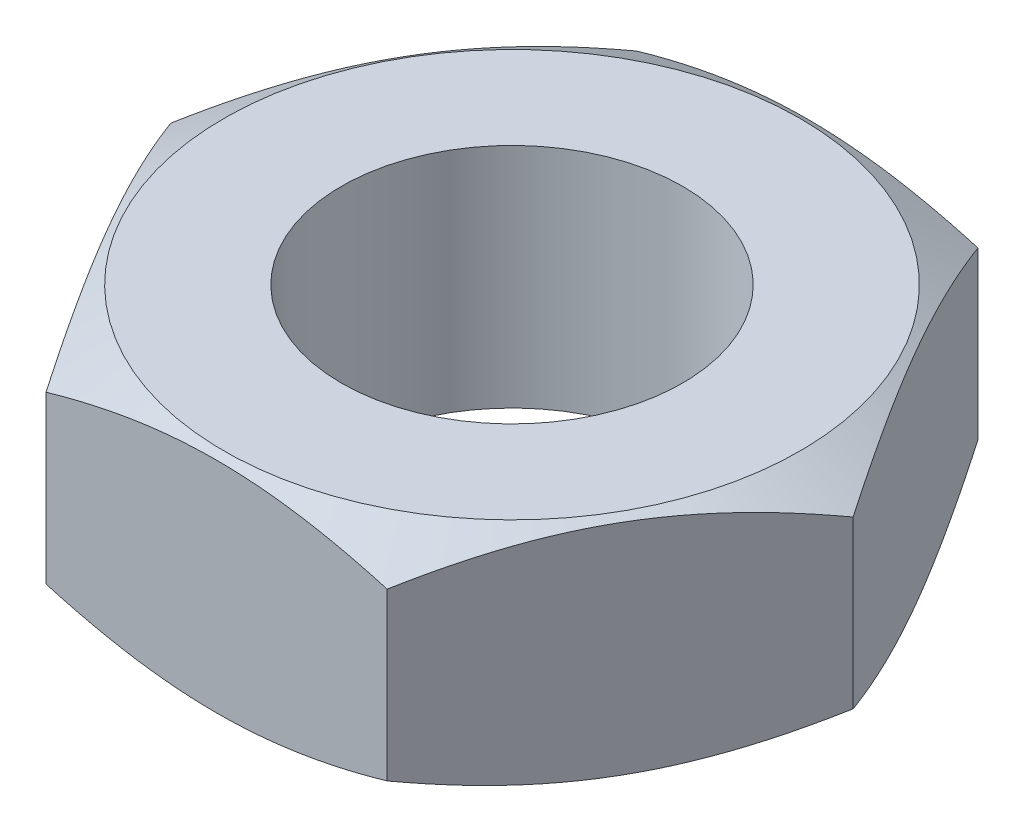
from build123d import *

# Parameters (mm, degrees)
BOSS_EXTRUDE1_DEPTH = 3
SKETCH3_R           = 4.5
CUT_EXTRUDE1_DEPTH  = 7


with BuildPart() as part:
    # Sketch2 → Boss-Extrude1 (new body, symmetric)
    with BuildSketch(Plane(origin=(0, 0, 0), x_dir=(1, 0, 0), z_dir=(0, 1, 0))):
        Polygon((-4.5, 7.794228634), (-9, 0), (-4.5, -7.794228634), (4.5, -7.794228634), (9, 0), (4.5, 7.794228634), align=None)
    extrude(amount=BOSS_EXTRUDE1_DEPTH, both=True)

    # Sketch3 → Cut-Extrude1 (cut, through all)
    with BuildSketch(Plane(origin=(0, 3, 0), x_dir=(1, 0, 0), z_dir=(0, 1, 0))):
        with Locations(Location((0, 0, 0), (0, 0, 270))):  # turned: the seam where the file's is
            Circle(SKETCH3_R)
    extrude(amount=-CUT_EXTRUDE1_DEPTH, mode=Mode.SUBTRACT)

    # Sketch10 → Cut-Revolve1 (revolve, cut)
    with BuildSketch(Plane.XY, mode=Mode.PRIVATE) as cut_revolve1_sk:
        Polygon((-9, 3), (-9, 2.191556781), (-7.599735269, 3), align=None)
    cut_revolve1 = revolve(cut_revolve1_sk.sketch.rotate(Axis((0, 0, 0), (0, 1, 0)), 90), axis=Axis((0, 0, 0), (0, 1, 0)), mode=Mode.SUBTRACT)  # turned: the seam where the file's is

    # Mirror1: Cut-Revolve1 across plane
    add(cut_revolve1.mirror(Plane.ZX), mode=Mode.SUBTRACT)


solid = part.part
